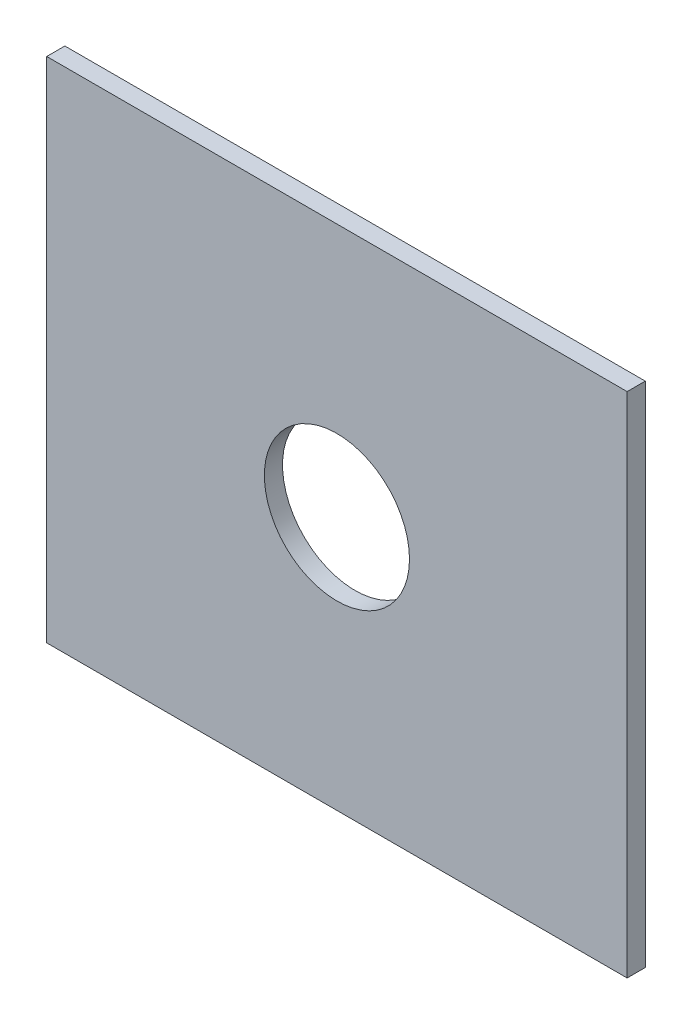
from build123d import *

# Parameters (mm, degrees)
SKETCH1_W          = 50.8
SKETCH1_H          = 44.45
EXTRUDE1_DEPTH     = 1.5875
SKETCH2_R          = 6.35
CUT_EXTRUDE1_DEPTH = 2.5875


with BuildPart() as part:
    # Sketch1 → Extrude1 (new body)
    with BuildSketch(Plane.XY):
        with Locations((0, 33.3375)):
            Rectangle(SKETCH1_W, SKETCH1_H)
    extrude(amount=EXTRUDE1_DEPTH)

    # Sketch2 → Cut-Extrude1 (cut, through all)
    with BuildSketch(Plane.XY.offset(1.5875)):
        with Locations((0, 33.3375)):
            Circle(SKETCH2_R)
    extrude(amount=-CUT_EXTRUDE1_DEPTH, mode=Mode.SUBTRACT)


solid = part.part
